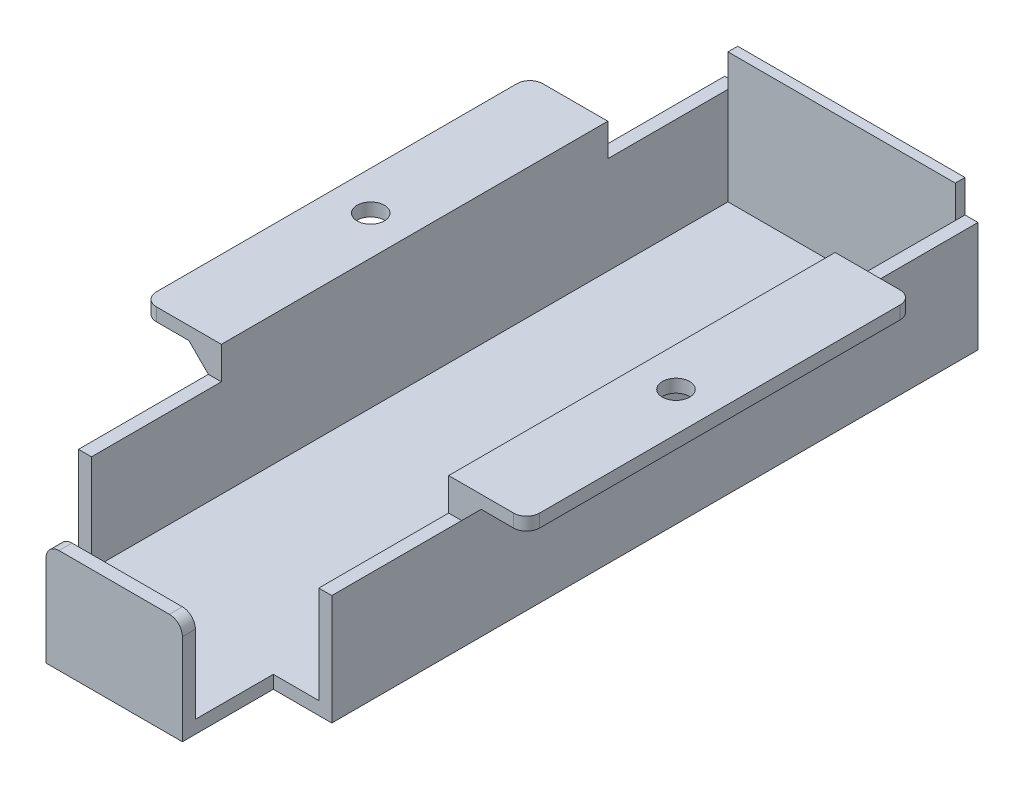
from build123d import *

# Parameters (mm, degrees)
BOSS_EXTRUDE1_DEPTH = 49
BOSS_EXTRUDE3_DEPTH = 10.5
CHAMFER1_SIZE       = 3
SKETCH4_R           = 2.1
CUT_EXTRUDE1_DEPTH  = 23
SKETCH5_W           = 8
SKETCH5_H           = 10
CUT_EXTRUDE2_DEPTH  = 21
BOSS_EXTRUDE5_DEPTH = 1.5
SKETCH6_W           = 12
SKETCH6_H           = 20
CUT_EXTRUDE3_DEPTH  = 5
FILLET1_R           = 2


with BuildPart() as part:
    # Sketch1 → Boss-Extrude1 (new body, symmetric)
    with BuildSketch(Plane.XY):
        Polygon((-29.5, 0), (-17.5, 0), (-17.5, -20), (17.5, -20), (17.5, 0), (29.5, 0), (29.5, -2), (19.5, -2), (19.5, -22), (-19.5, -22), (-19.5, -2), (-29.5, -2), align=None)
    extrude(amount=BOSS_EXTRUDE1_DEPTH, both=True)

    # Sketch3 → Boss-Extrude3 (add, symmetric)
    with BuildSketch(Plane(origin=(0, 0, 0), x_dir=(0, 0, -1), z_dir=(1, 0, 0))):
        Polygon((-49, -22), (-63, -22), (-63, -6), (-61, -6), (-61, -20), (-49, -20), align=None)
    extrude(amount=BOSS_EXTRUDE3_DEPTH, both=True)

    # Chamfer1
    chamfer1_edges = [part.edges().sort_by_distance(p)[0] for p in [
        (19.5, -2, 0),
        (-19.5, -2, 0),
    ]]
    chamfer(chamfer1_edges, length=CHAMFER1_SIZE)

    # Sketch4 → Cut-Extrude1 (cut, through all)
    with BuildSketch(Plane(origin=(0, 0, 0), x_dir=(1, 0, 0), z_dir=(0, 1, 0))):
        with Locations((-23.5, 0)):
            Circle(SKETCH4_R)
        with Locations((23.5, 0)):
            Circle(SKETCH4_R)
    extrude(amount=-CUT_EXTRUDE1_DEPTH, mode=Mode.SUBTRACT)

    # Sketch5 → Cut-Extrude2 (cut, through all)
    with BuildSketch(Plane.XZ.offset(2)):
        with Locations((23.5, 0)):
            Rectangle(SKETCH5_W, SKETCH5_H)
        with Locations((-23.5, 0)):
            Rectangle(SKETCH5_W, SKETCH5_H)
    extrude(amount=CUT_EXTRUDE2_DEPTH, mode=Mode.SUBTRACT)

    # Sketch2 → Boss-Extrude5 (add)
    with BuildSketch(Plane(origin=(0, 0, -49), x_dir=(-1, 0, 0), z_dir=(0, 0, -1))):
        Polygon((-17.5, 0), (17.5, 0), (29.5, 0), (29.5, -2), (22.5, -2), (19.5, -5), (19.5, -22), (-19.5, -22), (-19.5, -5), (-22.5, -2), (-29.5, -2), (-29.5, 0), align=None)
    extrude(amount=BOSS_EXTRUDE5_DEPTH)

    # Sketch6 → Cut-Extrude3 (cut)
    with BuildSketch(Plane(origin=(0, 0, 0), x_dir=(1, 0, 0), z_dir=(0, 1, 0))):
        with Locations((-23.5, -39)):
            Rectangle(SKETCH6_W, SKETCH6_H)
        with Locations((23.5, -39)):
            Rectangle(SKETCH6_W, SKETCH6_H)
        with Locations((23.5, 40.5)):
            Rectangle(SKETCH6_W, SKETCH6_H)
        with Locations((-23.5, 40.5)):
            Rectangle(SKETCH6_W, SKETCH6_H)
    extrude(amount=-CUT_EXTRUDE3_DEPTH, mode=Mode.SUBTRACT)

    # Fillet1
    fillet1_edges = [part.edges().sort_by_distance(p)[0] for p in [
        (-29.5, -1, -30.5),
        (29.5, -1, -30.5),
        (29.5, -1, 29),
        (-29.5, -1, 29),
        (-10.5, -6, 62),
        (10.5, -6, 62),
    ]]
    fillet(fillet1_edges, radius=FILLET1_R)


solid = part.part
